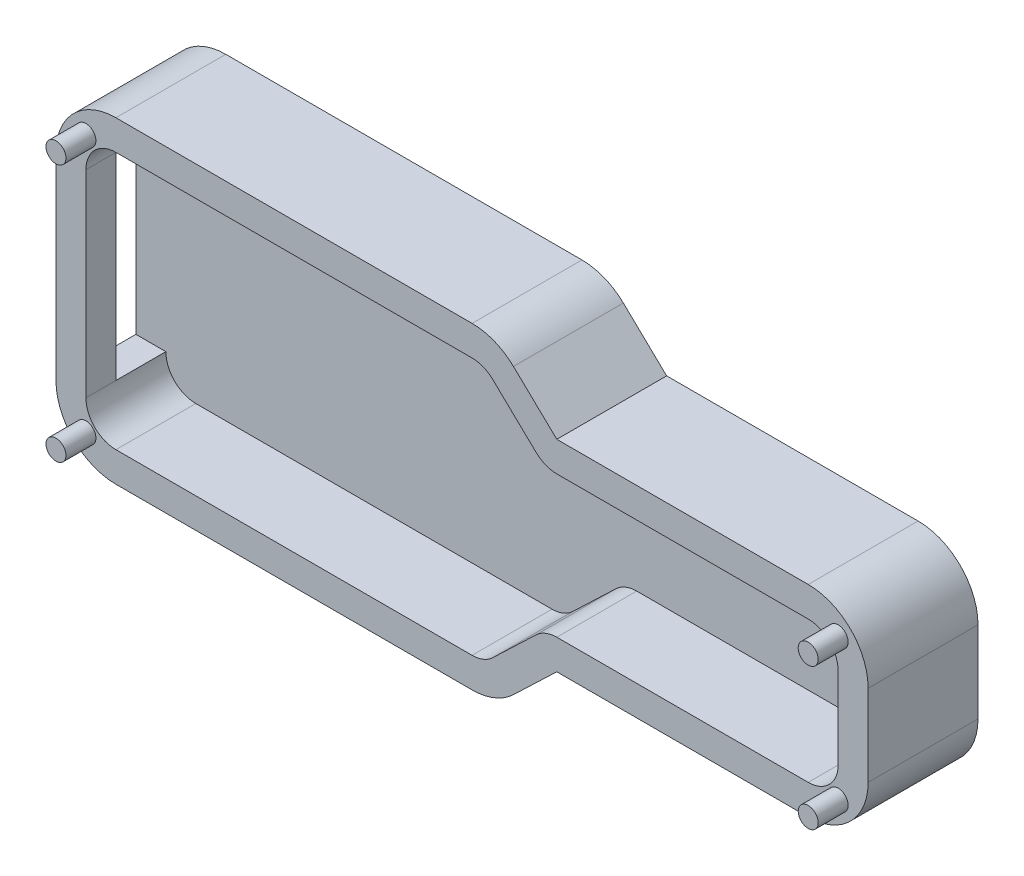
from build123d import *

# Parameters (mm, degrees)
SKETCH3_R                = 1
BOSS_EXTRUDE2_DEPTH      = 8
BOSS_EXTRUDE2_DEPTH_BACK = 3
BOSS_EXTRUDE3_DEPTH      = 3
SKETCH7_R                = 1
BOSS_EXTRUDE4_DEPTH      = 3
BOSS_EXTRUDE4_DEPTH_BACK = 11
SKETCH9_W                = 5
SKETCH9_H                = 19.78
CUT_EXTRUDE2_DEPTH       = 10


with BuildPart() as part:
    # Sketch3 → Boss-Extrude2 (new, two sides)
    with BuildSketch(Plane.XY) as boss_extrude2_sk:
        with BuildLine():
            Line((-70.31, 20.97), (-34.65285742, 20.97))
            ThreePointArc((-34.65285742, 20.97), (-32.418966384, 20.53863815), (-30.506280473, 19.306576947))
            Line((-30.506280473, 19.306576947), (-26.169703525, 15.16))
            Line((-26.169703525, 15.16), (-1, 15.16))
            ThreePointArc((-1, 15.16), (3.242640687, 13.402640687), (5, 9.16))
            Line((5, 9.16), (5, 1))
            ThreePointArc((5, 1), (3.242640687, -3.242640687), (-1, -5))
            Line((-1, -5), (-26.169703525, -5))
            Line((-26.169703525, -5), (-30.506280473, -9.146576947))
            ThreePointArc((-30.506280473, -9.146576947), (-32.418966384, -10.37863815), (-34.65285742, -10.81))
            Line((-34.65285742, -10.81), (-70.31, -10.81))
            ThreePointArc((-70.31, -10.81), (-74.552640687, -9.052640687), (-76.31, -4.81))
            Line((-76.31, -4.81), (-76.31, 14.97))
            ThreePointArc((-76.31, 14.97), (-74.552640687, 19.212640687), (-70.31, 20.97))
        make_face()
        with Locations((-73.31, 17.97)):
            Circle(SKETCH3_R, mode=Mode.SUBTRACT)
        with Locations((-73.31, -7.81)):
            Circle(SKETCH3_R, mode=Mode.SUBTRACT)
        with Locations((2, -2)):
            Circle(SKETCH3_R, mode=Mode.SUBTRACT)
        with Locations((2, 12.16)):
            Circle(SKETCH3_R, mode=Mode.SUBTRACT)
        with BuildLine():
            Line((-70.31, 17.97), (-34.65285742, 17.97))
            ThreePointArc((-34.65285742, 17.97), (-33.535911902, 17.754319075), (-32.579568946, 17.138288474))
            Line((-32.579568946, 17.138288474), (-28.242991999, 12.991711526))
            ThreePointArc((-28.242991999, 12.991711526), (-27.286649043, 12.375680925), (-26.169703525, 12.16))
            Line((-26.169703525, 12.16), (-1, 12.16))
            ThreePointArc((-1, 12.16), (1.121320344, 11.281320344), (2, 9.16))
            Line((2, 9.16), (2, 1))
            ThreePointArc((2, 1), (1.121320344, -1.121320344), (-1, -2))
            Line((-1, -2), (-26.169703525, -2))
            ThreePointArc((-26.169703525, -2), (-27.286649043, -2.215680925), (-28.242991999, -2.831711526))
            Line((-28.242991999, -2.831711526), (-32.579568946, -6.978288474))
            ThreePointArc((-32.579568946, -6.978288474), (-33.535911902, -7.594319075), (-34.65285742, -7.81))
            Line((-34.65285742, -7.81), (-70.31, -7.81))
            ThreePointArc((-70.31, -7.81), (-72.431320344, -6.931320344), (-73.31, -4.81))
            Line((-73.31, -4.81), (-73.31, 14.97))
            ThreePointArc((-73.31, 14.97), (-72.431320344, 17.091320344), (-70.31, 17.97))
        make_face(mode=Mode.SUBTRACT)
    extrude(amount=BOSS_EXTRUDE2_DEPTH)
    extrude(boss_extrude2_sk.sketch, amount=-BOSS_EXTRUDE2_DEPTH_BACK)

    # Sketch5 → Boss-Extrude3 (add)
    with BuildSketch(Plane(origin=(0, 0, -3), x_dir=(-1, 0, 0), z_dir=(0, 0, -1))):
        with BuildLine():
            Line((73.31, 14.97), (73.31, -4.81))
            ThreePointArc((73.31, -4.81), (72.431320344, -6.931320344), (70.31, -7.81))
            Line((70.31, -7.81), (34.65285742, -7.81))
            ThreePointArc((34.65285742, -7.81), (33.535911902, -7.594319075), (32.579568946, -6.978288474))
            Line((32.579568946, -6.978288474), (28.242991999, -2.831711526))
            ThreePointArc((28.242991999, -2.831711526), (27.286649043, -2.215680925), (26.169703525, -2))
            Line((26.169703525, -2), (1, -2))
            ThreePointArc((1, -2), (-1.121320344, -1.121320344), (-2, 1))
            Line((-2, 1), (-2, 9.16))
            ThreePointArc((-2, 9.16), (-1.121320344, 11.281320344), (1, 12.16))
            Line((1, 12.16), (26.169703525, 12.16))
            ThreePointArc((26.169703525, 12.16), (27.286649043, 12.375680925), (28.242991999, 12.991711526))
            Line((28.242991999, 12.991711526), (32.579568946, 17.138288474))
            ThreePointArc((32.579568946, 17.138288474), (33.535911902, 17.754319075), (34.65285742, 17.97))
            Line((34.65285742, 17.97), (70.31, 17.97))
            ThreePointArc((70.31, 17.97), (72.431320344, 17.091320344), (73.31, 14.97))
        make_face()
    extrude(amount=-BOSS_EXTRUDE3_DEPTH)

    # Sketch7 → Boss-Extrude4 (add, two sides)
    with BuildSketch(Plane.XY.offset(8)) as boss_extrude4_sk:
        with Locations((-73.31, 17.97)):
            Circle(SKETCH7_R)
        with Locations((2, -2)):
            Circle(SKETCH7_R)
        with Locations((2, 12.16)):
            Circle(SKETCH7_R)
        with Locations((-73.31, -7.81)):
            Circle(SKETCH7_R)
    extrude(amount=BOSS_EXTRUDE4_DEPTH)
    extrude(boss_extrude4_sk.sketch, amount=-BOSS_EXTRUDE4_DEPTH_BACK)

    # Sketch9 → Cut-Extrude2 (cut)
    with BuildSketch(Plane.ZY.offset(76.31)):
        with Locations((2.5, 5.08)):
            Rectangle(SKETCH9_W, SKETCH9_H)
    extrude(amount=-CUT_EXTRUDE2_DEPTH, mode=Mode.SUBTRACT)


solid = part.part
